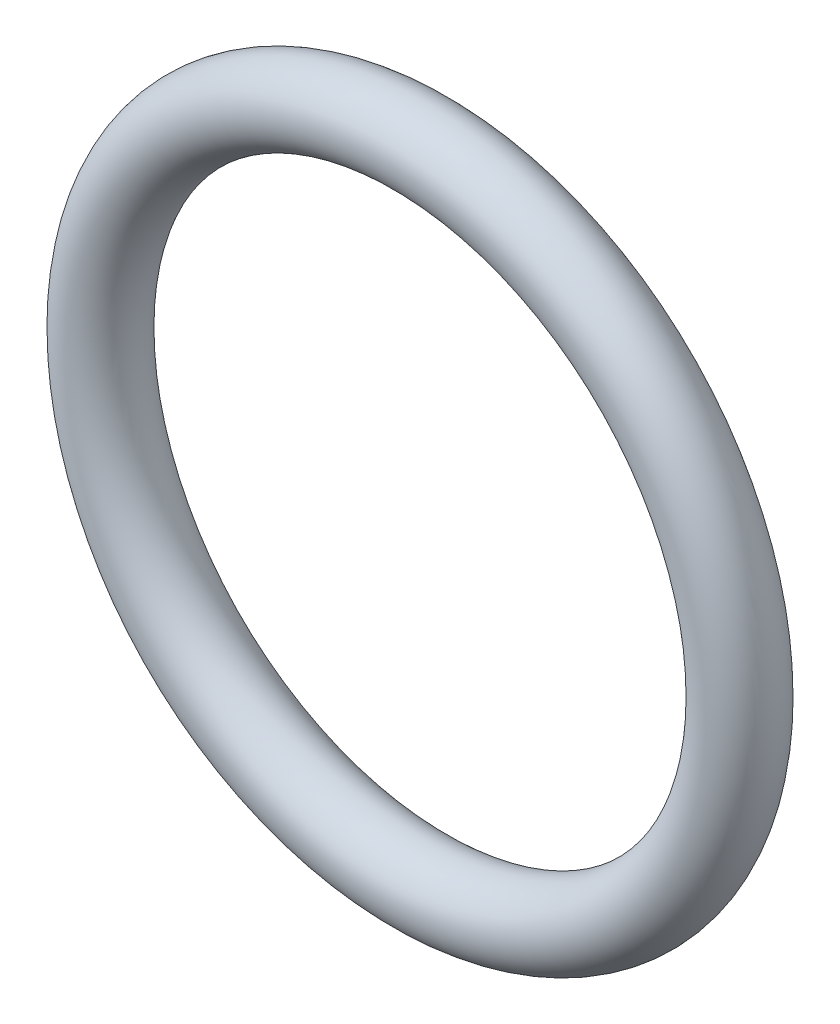
from build123d import *

# Parameters (mm, degrees)
ESQUISSE1_R = 0.9


with BuildPart() as part:
    # Esquisse1 → Révolution1 (revolve)
    with BuildSketch(Plane(origin=(0, 0, 0), x_dir=(1, 0, 0), z_dir=(0, 1, 0))):
        with Locations((-7.6, 0)):
            Circle(ESQUISSE1_R)
    revolve(axis=Axis((0, 0, -4.370899565), (0, 0, 1)))


solid = part.part
